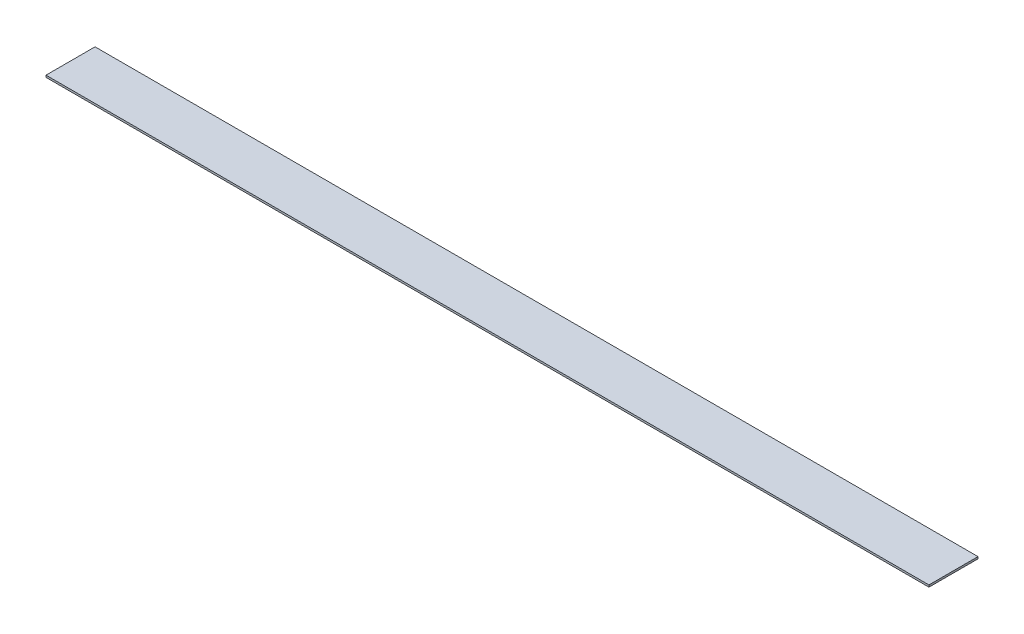
from build123d import *

# Parameters (mm, degrees)
SKETCH1_W           = 450
SKETCH1_H           = 25
BOSS_EXTRUDE1_DEPTH = 1


with BuildPart() as part:
    # Sketch1 → Boss-Extrude1 (new body)
    with BuildSketch(Plane(origin=(0, 0, 0), x_dir=(1, 0, 0), z_dir=(0, 1, 0))):
        Rectangle(SKETCH1_W, SKETCH1_H)
    extrude(amount=BOSS_EXTRUDE1_DEPTH)


solid = part.part
